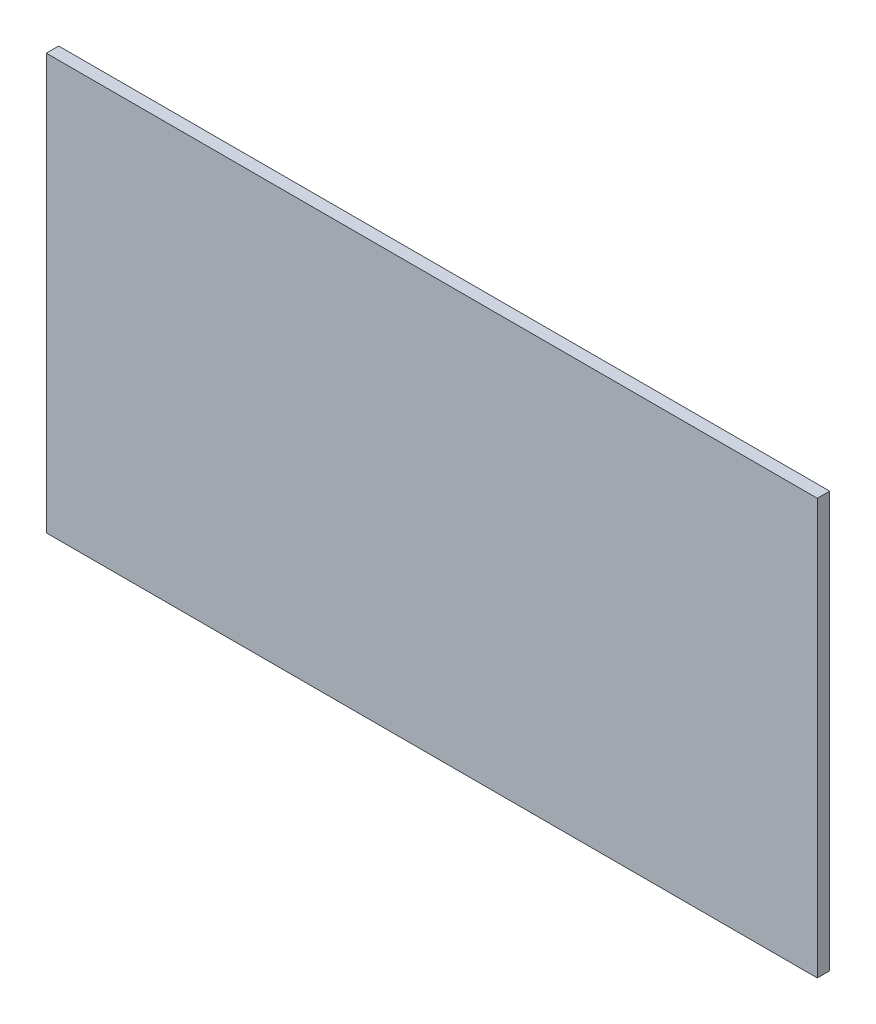
from build123d import *

# Parameters (mm, degrees)
SKETCH1_W           = 228.948077088
SKETCH1_H           = 335.28
SKETCH1_W_2         = 80.13086011
SKETCH1_W_3         = 313.150604536
BOSS_EXTRUDE1_DEPTH = 10


with BuildPart() as part:
    # Sketch1 → Boss-Extrude1 (new body)
    with BuildSketch(Plane.XY):
        with Locations((-200.573840909, -9.426974547)):
            Rectangle(SKETCH1_W, SKETCH1_H)
        with Locations((-46.03437231, -9.426974547)):
            Rectangle(SKETCH1_W_2, SKETCH1_H)
        with Locations((150.606360013, -9.426974547)):
            Rectangle(SKETCH1_W_3, SKETCH1_H)
    extrude(amount=BOSS_EXTRUDE1_DEPTH)


solid = part.part
